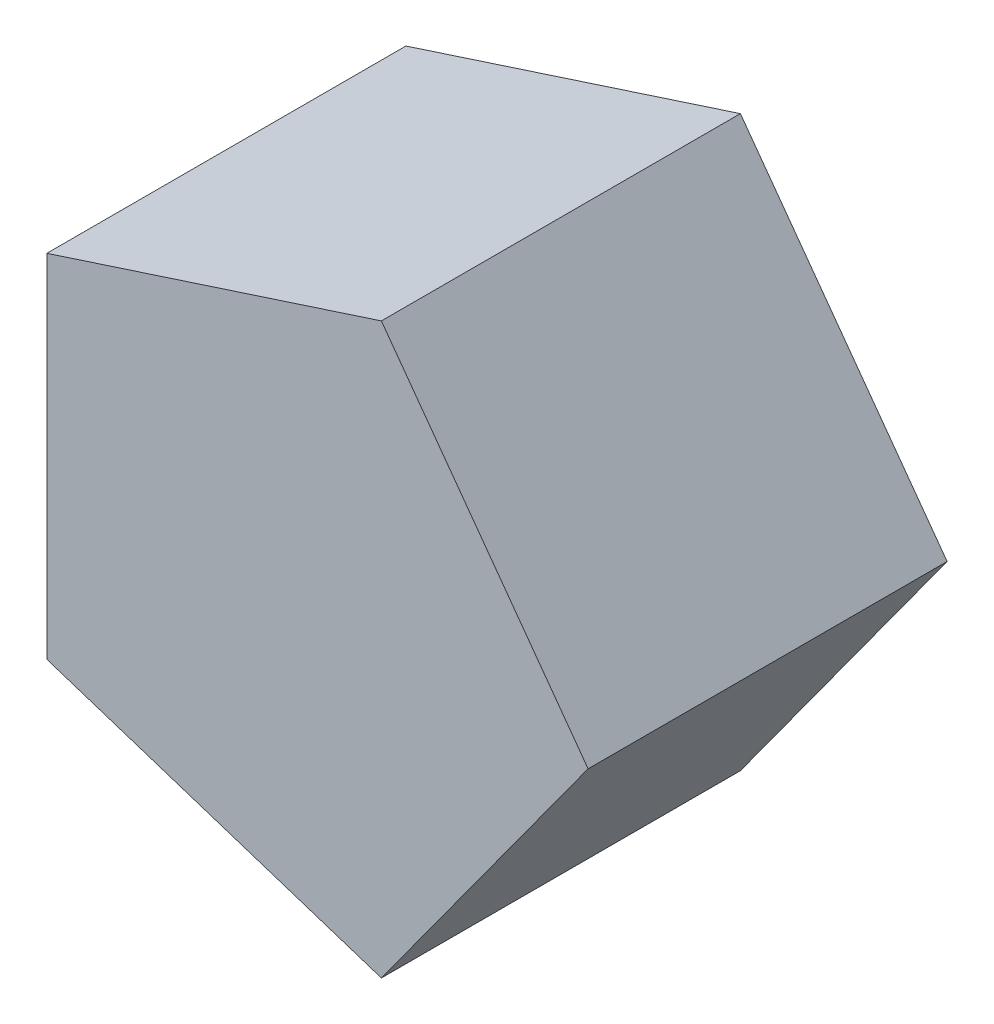
from build123d import *

# Parameters (mm, degrees)
ESTRUSIONE_ESTRUSIONE1_DEPTH = 30


with BuildPart() as part:
    # Schizzo1 → Estrusione-Estrusione1 (new body)
    with BuildSketch(Plane.XY):
        Polygon((25, 0), (7.725424859, 23.776412907), (-20.225424859, 14.694631307), (-20.225424859, -14.694631307), (7.725424859, -23.776412907), align=None)
    extrude(amount=ESTRUSIONE_ESTRUSIONE1_DEPTH)


solid = part.part
